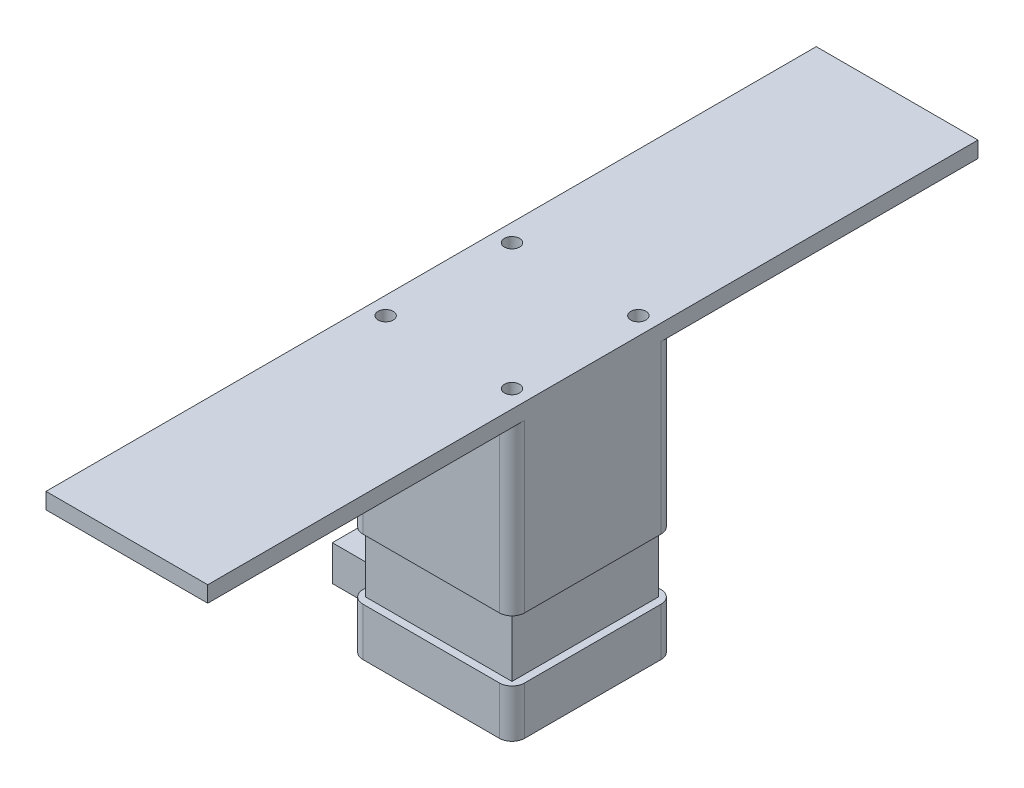
from build123d import *

# Parameters (mm, degrees)
BOSS_EXTRUDE1_DEPTH = 19
SKETCH3_W           = 58
SKETCH3_H           = 58
BOSS_EXTRUDE2_DEPTH = 24
BOSS_EXTRUDE3_DEPTH = 66
SKETCH6_W           = 28
SKETCH6_H           = 14
BOSS_EXTRUDE4_DEPTH = 25.1
SKETCH7_W           = 64
SKETCH7_H           = 304.8
BOSS_EXTRUDE5_DEPTH = 6.35
SKETCH8_R           = 3
CUT_EXTRUDE1_DEPTH  = 5


with BuildPart() as part:
    # Sketch2 → Boss-Extrude1 (new body)
    with BuildSketch(Plane(origin=(0, 0, 0), x_dir=(1, 0, 0), z_dir=(0, 1, 0))):
        with BuildLine():
            Line((5, 0), (59, 0))
            ThreePointArc((59, 0), (62.535533906, -1.464466094), (64, -5))
            Line((64, -5), (64, -59))
            ThreePointArc((64, -59), (62.535533906, -62.535533906), (59, -64))
            Line((59, -64), (5, -64))
            ThreePointArc((5, -64), (1.464466094, -62.535533906), (0, -59))
            Line((0, -59), (0, -5))
            ThreePointArc((0, -5), (1.464466094, -1.464466094), (5, 0))
        make_face()
    extrude(amount=BOSS_EXTRUDE1_DEPTH)

    # Sketch3 → Boss-Extrude2 (add)
    with BuildSketch(Plane(origin=(0, 19, 0), x_dir=(1, 0, 0), z_dir=(0, 1, 0))):
        with Locations((32, -32)):
            Rectangle(SKETCH3_W, SKETCH3_H)
    extrude(amount=BOSS_EXTRUDE2_DEPTH)

    # Sketch4 → Boss-Extrude3 (add)
    with BuildSketch(Plane(origin=(0, 43, 0), x_dir=(1, 0, 0), z_dir=(0, 1, 0))):
        with BuildLine():
            Line((5, 0), (59, 0))
            ThreePointArc((59, 0), (62.535533906, -1.464466094), (64, -5))
            Line((64, -5), (64, -58.999541839))
            ThreePointArc((64, -58.999541839), (62.535533906, -62.535075745), (59, -63.999541839))
            Line((59, -63.999541839), (5, -63.999541839))
            ThreePointArc((5, -63.999541839), (1.464466094, -62.535075745), (0, -58.999541839))
            Line((0, -58.999541839), (0, -5))
            ThreePointArc((0, -5), (1.464466094, -1.464466094), (5, 0))
        make_face()
    extrude(amount=BOSS_EXTRUDE3_DEPTH)

    # Sketch6 → Boss-Extrude4 (add)
    with BuildSketch(Plane.ZY):
        with Locations((32, 9)):
            Rectangle(SKETCH6_W, SKETCH6_H)
    extrude(amount=BOSS_EXTRUDE4_DEPTH)

    # Sketch7 → Boss-Extrude5 (add)
    with BuildSketch(Plane(origin=(0, 109, 0), x_dir=(1, 0, 0), z_dir=(0, 1, 0))):
        with Locations((32, -32)):
            Rectangle(SKETCH7_W, SKETCH7_H)
    extrude(amount=BOSS_EXTRUDE5_DEPTH)

    # Sketch8 → Cut-Extrude1 (cut)
    with BuildSketch(Plane(origin=(0, 115.35, 0), x_dir=(1, 0, 0), z_dir=(0, 1, 0))):
        with BuildLine():
            ThreePointArc((7, -10), (9.121320344, -9.121320344), (10, -7))
            Line((10, -7), (7, -7))
            Line((7, -7), (7, -10))
        make_face()
        with BuildLine():
            Line((7, -7), (10, -7))
            ThreePointArc((10, -7), (4.878679656, -4.878679656), (7, -10))
            Line((7, -10), (7, -7))
        make_face()
        with Locations((57, -7)):
            Circle(SKETCH8_R)
        with Locations((57, -57)):
            Circle(SKETCH8_R)
        with Locations((7, -57)):
            Circle(SKETCH8_R)
    extrude(amount=-CUT_EXTRUDE1_DEPTH, mode=Mode.SUBTRACT)


solid = part.part
